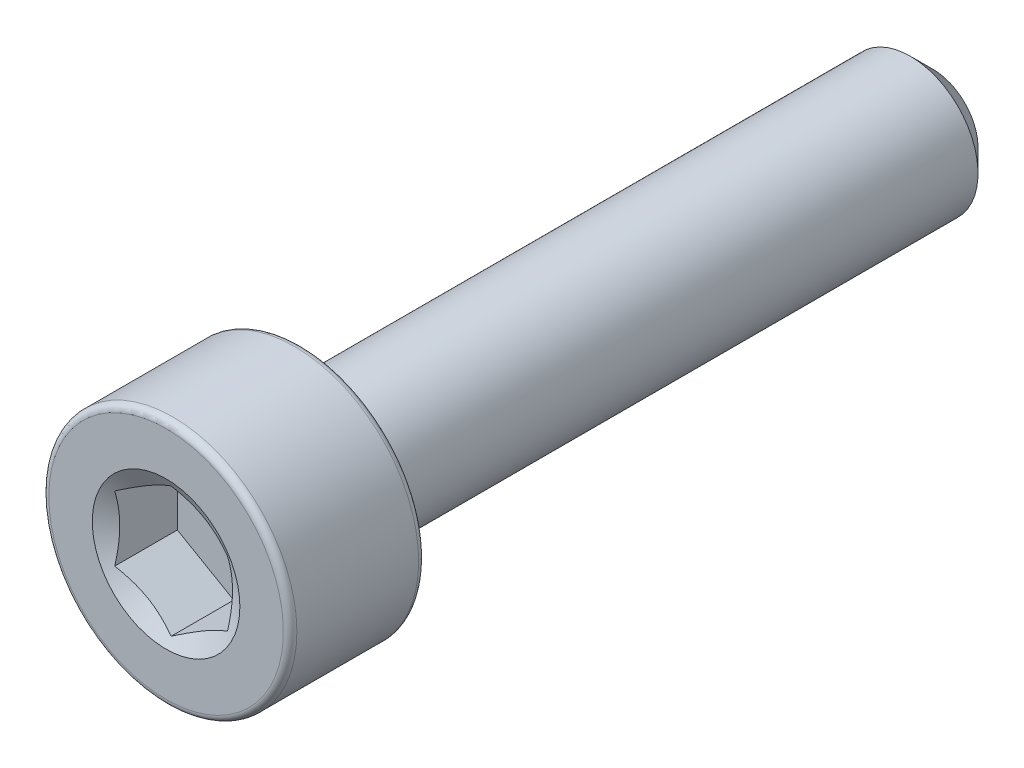
from build123d import *

# Parameters (mm, degrees)
CUT_EXTRUDE1_START = 8.5
CUT_EXTRUDE1_DEPTH = 1.5


with BuildPart() as part:
    # Sketch2 → Revolve1 (revolve)
    with BuildSketch(Plane(origin=(0, 0, 0), x_dir=(0, 0, -1), z_dir=(1, 0, 0)), mode=Mode.PRIVATE) as revolve1_sk:
        with BuildLine():
            Line((8.5, 0), (8.5, 1))
            Line((8.5, 1), (8, 1.5))
            Line((8, 1.5), (-5.5, 1.5))
            Line((-5.5, 1.5), (-5.5, 2.6))
            ThreePointArc((-5.5, 2.6), (-5.543933983, 2.706066017), (-5.65, 2.75))
            Line((-5.65, 2.75), (-8.35, 2.75))
            ThreePointArc((-8.35, 2.75), (-8.456066017, 2.706066017), (-8.5, 2.6))
            Line((-8.5, 2.6), (-8.5, 0))
            Line((-8.5, 0), (8.5, 0))
        make_face()
    revolve(revolve1_sk.sketch.rotate(Axis((0, 0, -8.5), (0, 0, 1)), 90), axis=Axis((0, 0, -8.5), (0, 0, 1)))

    # Sketch3 → Cut-Extrude1 (cut)
    with BuildSketch(Plane.XY.offset(CUT_EXTRUDE1_START)):
        Polygon((-1.25, 0.721687836), (-1.25, -0.721687836), (0, -1.443375673), (1.25, -0.721687836), (1.25, 0.721687836), (0, 1.443375673), align=None)
    extrude(amount=-CUT_EXTRUDE1_DEPTH, mode=Mode.SUBTRACT)

    # Cut-Extrude2 cone 1 section (through the dimple's axis) → Cut-Extrude2 (revolve, cut)
    with BuildSketch(Plane(origin=(0, 0, 8.5), x_dir=(0, -1, 0), z_dir=(1, 0, 0))):
        Polygon((0, 0), (1.636146394, 0), (0, 0.944629561), align=None)
    revolve(axis=Axis((0, 0, 8.5), (0, 0, -1)), mode=Mode.SUBTRACT)


solid = part.part
